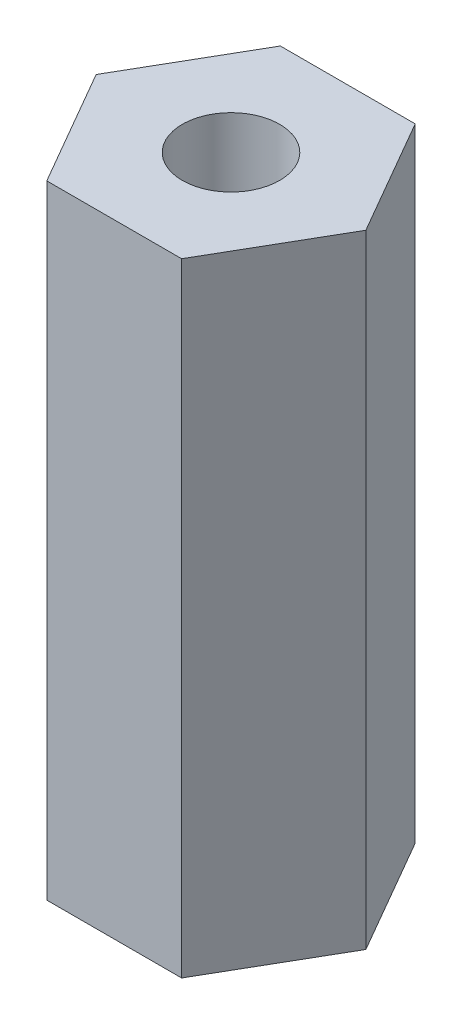
from build123d import *

# Parameters (mm, degrees)
BOSS_EXTRUDE1_DEPTH   = 16
M3X0_5_TAPPED_HOLE1_D = 2.5


with BuildPart() as part:
    # Sketch1 → Boss-Extrude1 (new body)
    with BuildSketch(Plane(origin=(0, 0, 0), x_dir=(1, 0, 0), z_dir=(0, 1, 0))):
        Polygon((1.732050808, 3), (-1.732050808, 3), (-3.464101615, 0), (-1.732050808, -3), (1.732050808, -3), (3.464101615, 0), align=None)
    extrude(amount=BOSS_EXTRUDE1_DEPTH)

    # M3x0.5 Tapped Hole1 (through all)
    with Locations(Plane(origin=(0, 16, 0), x_dir=(-1, 0, 0), z_dir=(0, 1, 0))):
        with Locations((0, 0)):
            Hole(M3X0_5_TAPPED_HOLE1_D / 2)


solid = part.part
